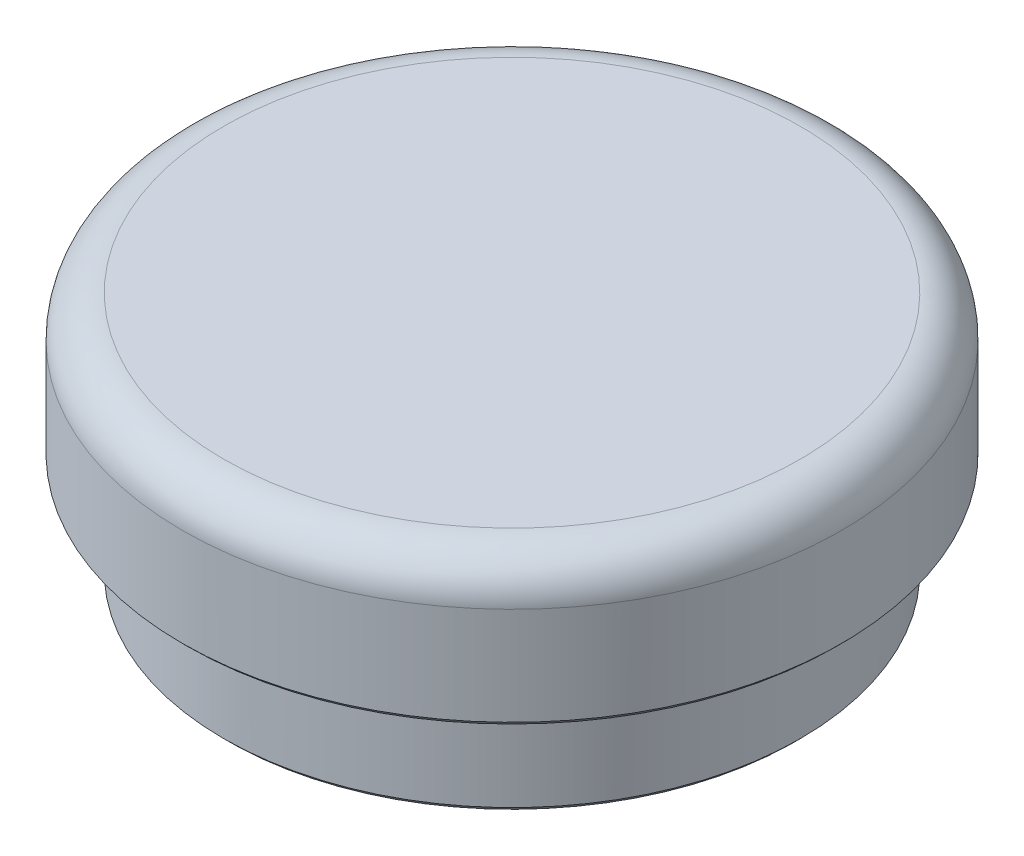
from build123d import *

# Parameters (mm, degrees)
FILLET1_R          = 2
SKETCH2_R          = 10
CUT_EXTRUDE1_DEPTH = 9
CHAMFER1_SIZE      = 0.25
CHAMFER2_SIZE      = 0.25


with BuildPart() as part:
    # Sketch1 → Revolve1 (revolve)
    with BuildSketch(Plane.XY):
        Polygon((0, 0), (-14, 0), (-14, 5), (-16, 5), (-16, 12), (0, 12), align=None)
    revolve(axis=Axis((0, 12, 0), (0, -1, 0)))

    # Fillet1
    fillet1_edges = [part.edges().sort_by_distance(p)[0] for p in [
        (16, 12, 0),
    ]]
    fillet(fillet1_edges, radius=FILLET1_R)

    # Sketch2 → Cut-Extrude1 (cut)
    with BuildSketch(Plane.XZ):
        Circle(SKETCH2_R)
    extrude(amount=-CUT_EXTRUDE1_DEPTH, mode=Mode.SUBTRACT)

    # Chamfer1
    chamfer1_edges = [part.edges().sort_by_distance(p)[0] for p in [
        (-10, 0, 0),
        (14, 0, 0),
    ]]
    chamfer(chamfer1_edges, length=CHAMFER1_SIZE)

    # Chamfer2
    chamfer2_edges = [part.edges().sort_by_distance(p)[0] for p in [
        (16, 5, 0),
    ]]
    chamfer(chamfer2_edges, length=CHAMFER2_SIZE)


solid = part.part
